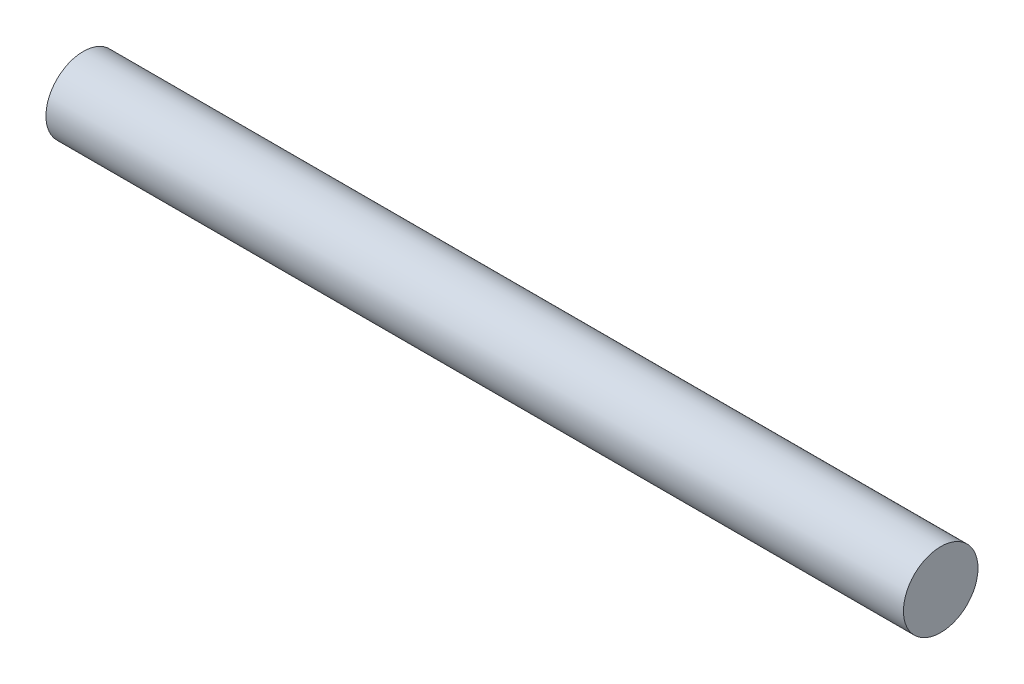
from build123d import *

# Parameters (mm, degrees)
SKETCH1_R           = 1
BOSS_EXTRUDE1_DEPTH = 11.5


with BuildPart() as part:
    # Sketch1 → Boss-Extrude1 (new body, symmetric)
    with BuildSketch(Plane(origin=(0, 0, 0), x_dir=(0, 0, -1), z_dir=(1, 0, 0))):
        Circle(SKETCH1_R)
    extrude(amount=BOSS_EXTRUDE1_DEPTH, both=True)


solid = part.part
